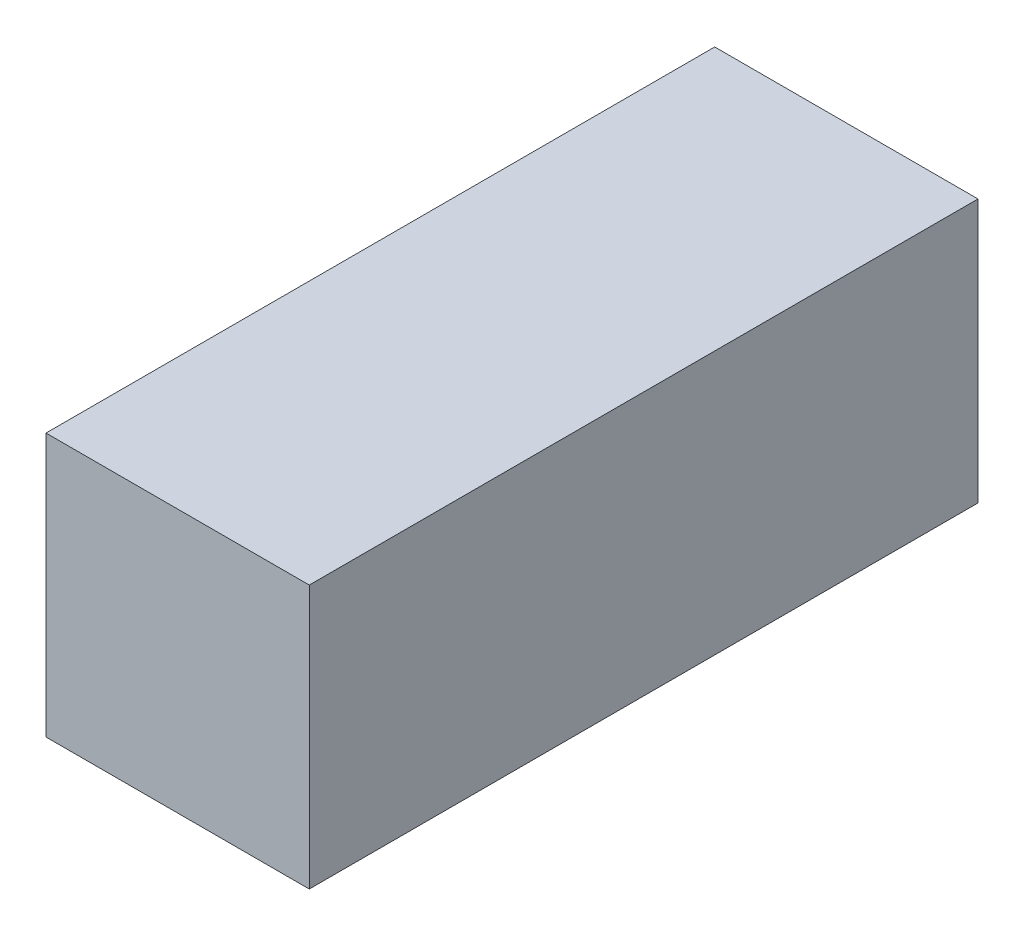
from build123d import *

# Parameters (mm, degrees)
SKETCH1_W           = 5
SKETCH1_H           = 5
BOSS_EXTRUDE1_DEPTH = 12.7


with BuildPart() as part:
    # Sketch1 → Boss-Extrude1 (new body)
    with BuildSketch(Plane.XY):
        with Locations((2.5799264, 2.5937066)):
            Rectangle(SKETCH1_W, SKETCH1_H)
    extrude(amount=BOSS_EXTRUDE1_DEPTH)


solid = part.part
